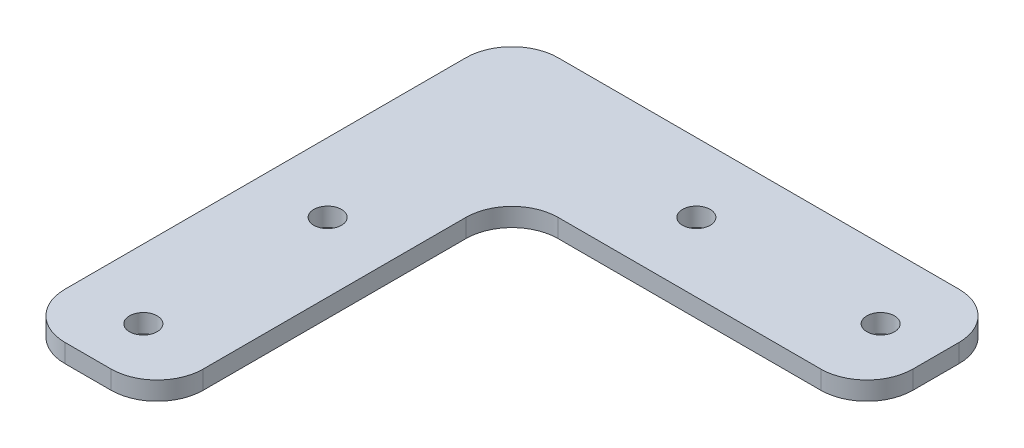
from build123d import *

# Parameters (mm, degrees)
SKETCH1_R           = 1.5
BOSS_EXTRUDE1_DEPTH = 2
FILLET1_R           = 5


with BuildPart() as part:
    # Sketch1 → Boss-Extrude1 (new body)
    with BuildSketch(Plane(origin=(0, 0, 0), x_dir=(1, 0, 0), z_dir=(0, 1, 0))):
        Polygon((7.5, -7.5), (7.5, -46), (-7.5, -46), (-7.5, 7.5), (46, 7.5), (46, -7.5), align=None)
        with Locations((0, -40)):
            Circle(SKETCH1_R, mode=Mode.SUBTRACT)
        with Locations((0, -20)):
            Circle(SKETCH1_R, mode=Mode.SUBTRACT)
        with Locations((20, 0)):
            Circle(SKETCH1_R, mode=Mode.SUBTRACT)
        with Locations((40, 0)):
            Circle(SKETCH1_R, mode=Mode.SUBTRACT)
    extrude(amount=BOSS_EXTRUDE1_DEPTH)

    # Fillet1
    fillet1_edges = [part.edges().sort_by_distance(p)[0] for p in [
        (7.5, 1, 7.5),
        (7.5, 1, 46),
        (-7.5, 1, 46),
        (-7.5, 1, -7.5),
        (46, 1, -7.5),
        (46, 1, 7.5),
    ]]
    fillet(fillet1_edges, radius=FILLET1_R)


solid = part.part
